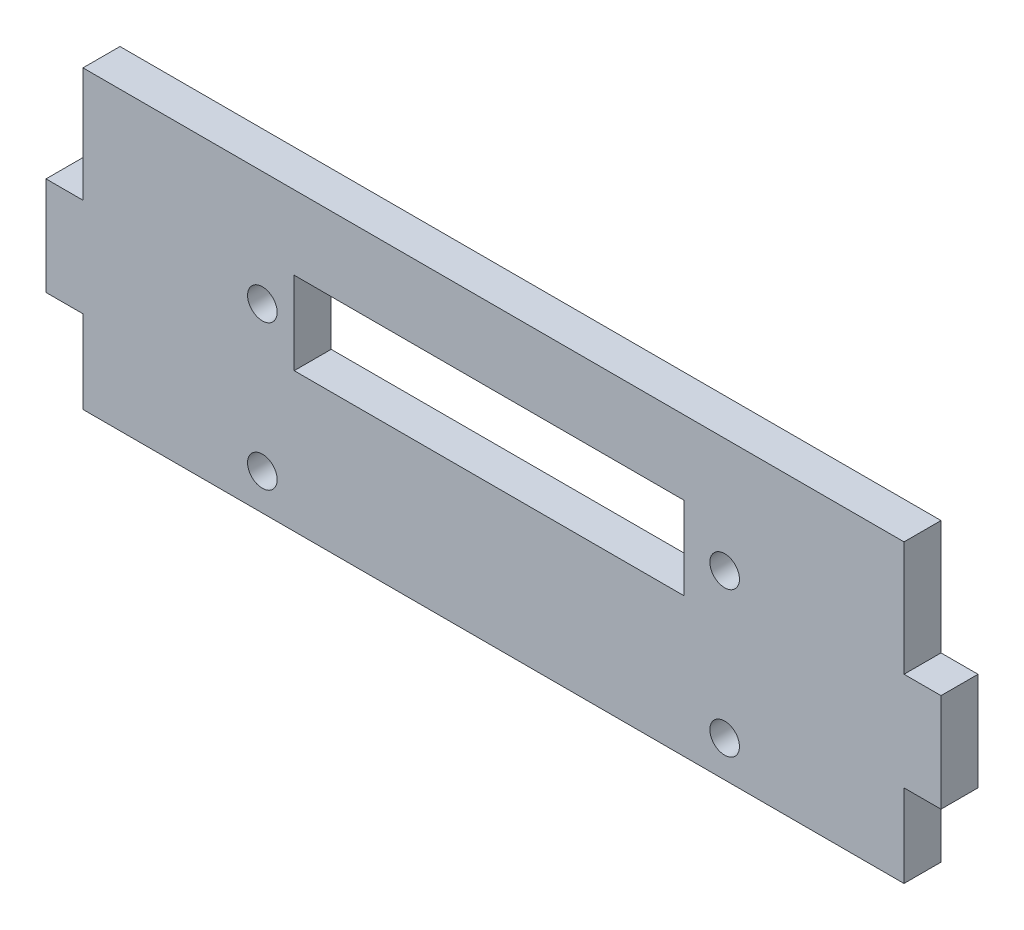
from build123d import *

# Parameters (mm, degrees)
CROQUIS1_W              = 111
CROQUIS1_H              = 40
SALIENTE_EXTRUIR1_DEPTH = 5
CROQUIS2_R              = 2
CROQUIS2_W              = 52.7
CROQUIS2_H              = 11.179597985
CORTAR_EXTRUIR1_DEPTH   = 10
CROQUIS3_W              = 5
CROQUIS3_H              = 13.3
SALIENTE_EXTRUIR2_DEPTH = 5
CROQUIS4_W              = 5
CROQUIS4_H              = 13.3
SALIENTE_EXTRUIR3_DEPTH = 5


with BuildPart() as part:
    # Croquis1 → Saliente-Extruir1 (new body)
    with BuildSketch(Plane.XY):
        with Locations((55.5, 20)):
            Rectangle(CROQUIS1_W, CROQUIS1_H)
    extrude(amount=SALIENTE_EXTRUIR1_DEPTH)

    # Croquis2 → Cortar-Extruir1 (cut)
    with BuildSketch(Plane.XY.offset(5)):
        with Locations((24.25, 24.5)):
            Circle(CROQUIS2_R)
        with Locations((86.75, 24.5)):
            Circle(CROQUIS2_R)
        with Locations((24.25, 4.9)):
            Circle(CROQUIS2_R)
        with Locations((86.75, 4.9)):
            Circle(CROQUIS2_R)
        with Locations((54.905498666, 24.410201008)):
            Rectangle(CROQUIS2_W, CROQUIS2_H)
    extrude(amount=-CORTAR_EXTRUIR1_DEPTH, mode=Mode.SUBTRACT)

    # Croquis3 → Saliente-Extruir2 (add)
    with BuildSketch(Plane.ZY):
        with Locations((2.5, 17.85)):
            Rectangle(CROQUIS3_W, CROQUIS3_H)
    extrude(amount=SALIENTE_EXTRUIR2_DEPTH)

    # Croquis4 → Saliente-Extruir3 (add)
    with BuildSketch(Plane(origin=(111, 0, 0), x_dir=(0, 0, -1), z_dir=(1, 0, 0))):
        with Locations((-2.5, 17.85)):
            Rectangle(CROQUIS4_W, CROQUIS4_H)
    extrude(amount=SALIENTE_EXTRUIR3_DEPTH)


solid = part.part
